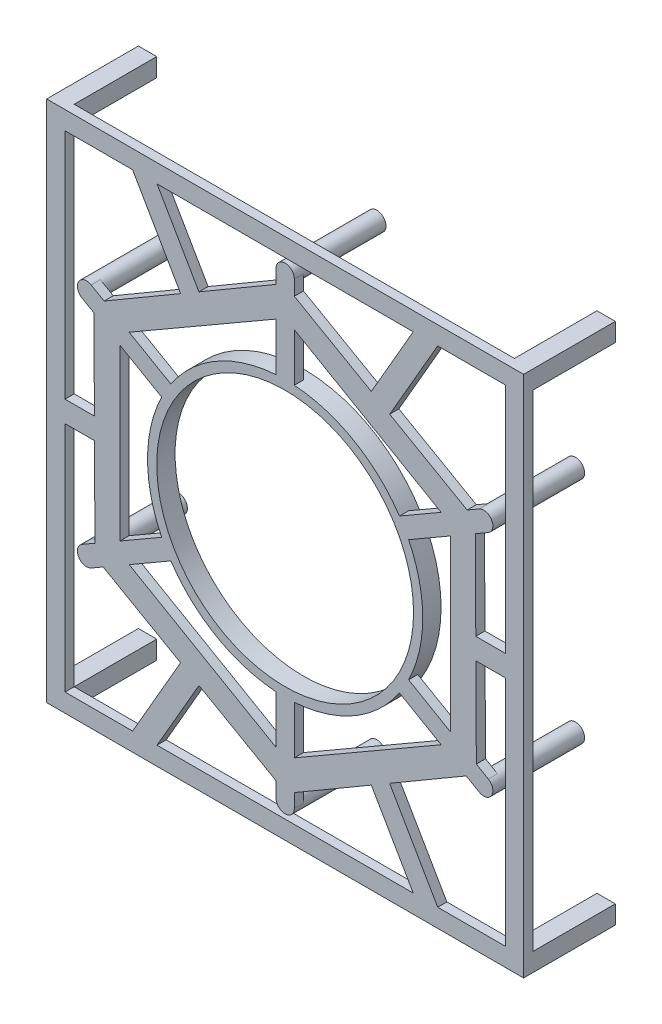
from build123d import *

# Parameters (mm, degrees)
BOSS_EXTRUDE1_DEPTH      = 3.175
BOSS_EXTRUDE2_DEPTH      = 3.175
BOSS_EXTRUDE3_DEPTH      = 3.175
SKETCH1_7_R              = 3.175
BOSS_EXTRUDE4_DEPTH      = 3.175
BOSS_EXTRUDE4_DEPTH_BACK = 28.575
BOSS_EXTRUDE5_DEPTH      = 3.175
BOSS_EXTRUDE5_DEPTH_BACK = 3.175
BOSS_EXTRUDE6_DEPTH      = 3.175
SKETCH1_10_W             = 6.35
SKETCH1_10_H             = 6.35
BOSS_EXTRUDE7_DEPTH      = 3.175
BOSS_EXTRUDE7_DEPTH_BACK = 28.575
SKETCH1_11_W             = 6.35
SKETCH1_11_H             = 80.471325791
BOSS_EXTRUDE8_DEPTH      = 3.175


with BuildPart() as part:
    # Sketch1 → Boss-Extrude1 (new body)
    with BuildSketch(Plane.XY):
        Polygon((-65.842778279, -34.348171554), (-57.167418256, -29.33945011), (-57.167418256, -3.666174209), (-65.993982871, -3.666174209), align=None)
        Polygon((-31.758709128, -47.675349374), (-53.992418256, -34.838711424), (-63.007288153, -40.043448985), (-36.190058785, -55.350672126), align=None)
        Polygon((-57.167418256, -33.005624319), (-57.167418256, -29.33945011), (-65.842778279, -34.348171554), (-65.822630715, -38.436456845), (-63.007288153, -40.043448985), (-53.992418256, -34.838711424), align=None)
        Polygon((-57.167418256, -3.666174209), (-57.167418256, 3.666174209), (-66.03011757, 3.666174209), (-65.993982871, -3.666174209), align=None)
        Polygon((-57.167418256, 3.666174209), (-57.167418256, 29.33945011), (-66.182288153, 34.544187671), (-66.03011757, 3.666174209), align=None)
        Polygon((-66.182288153, 34.544187671), (-57.167418256, 29.33945011), (-57.167418256, 33.005624319), (-53.992418256, 34.838711424), (-62.667778279, 39.847432868), (-66.198263417, 37.785841921), align=None)
        Polygon((-62.667778279, 39.847432868), (-53.992418256, 34.838711424), (-31.758709128, 47.675349374), (-36.171991435, 55.319378558), align=None)
        Polygon((-31.758709128, 47.675349374), (-25.408709128, 51.341523583), (-29.840058785, 59.016846335), (-36.171991435, 55.319378558), align=None)
        Polygon((-25.408709128, 51.341523583), (-3.175, 64.178161534), (-3.175, 74.587636656), (-29.840058785, 59.016846335), align=None)
        Polygon((-3.175, 74.587636656), (-3.175, 64.178161534), (0, 66.011248638), (3.175, 64.178161534), (3.175, 74.195604423), (-0.375632701, 76.222298766), align=None)
        Polygon((3.175, 74.195604423), (3.175, 64.178161534), (25.408709128, 51.341523583), (29.821991435, 58.985552768), align=None)
        Polygon((29.821991435, 58.985552768), (25.408709128, 51.341523583), (31.758709128, 47.675349374), (36.190058785, 55.350672126), align=None)
        Polygon((31.758709128, 47.675349374), (53.992418256, 34.838711424), (63.007288153, 40.043448985), (36.190058785, 55.350672126), align=None)
        Polygon((65.842778279, 34.348171554), (57.167418256, 29.33945011), (57.167418256, 3.666174209), (65.993982871, 3.666174209), align=None)
        Polygon((57.167418256, 33.005624319), (57.167418256, 29.33945011), (65.842778279, 34.348171554), (65.822630715, 38.436456845), (63.007288153, 40.043448985), (53.992418256, 34.838711424), align=None)
        Polygon((57.167418256, 3.666174209), (57.167418256, -3.666174209), (66.03011757, -3.666174209), (65.993982871, 3.666174209), align=None)
        Polygon((57.167418256, -3.666174209), (57.167418256, -29.33945011), (66.182288153, -34.544187671), (66.03011757, -3.666174209), align=None)
        Polygon((57.167418256, -33.005624319), (53.992418256, -34.838711424), (62.667778279, -39.847432868), (66.198263417, -37.785841921), (66.182288153, -34.544187671), (57.167418256, -29.33945011), align=None)
        Polygon((62.667778279, -39.847432868), (53.992418256, -34.838711424), (31.758709128, -47.675349374), (36.171991435, -55.319378558), align=None)
        Polygon((36.171991435, -55.319378558), (31.758709128, -47.675349374), (25.408709128, -51.341523583), (29.840058785, -59.016846335), align=None)
        Polygon((25.408709128, -51.341523583), (3.175, -64.178161534), (3.175, -74.587636656), (29.840058785, -59.016846335), align=None)
        Polygon((0, -66.011248638), (-3.175, -64.178161534), (-3.175, -74.195604423), (0.375632701, -76.222298766), (3.175, -74.587636656), (3.175, -64.178161534), align=None)
        Polygon((-3.175, -74.195604423), (-3.175, -64.178161534), (-25.408709128, -51.341523583), (-29.821991435, -58.985552768), align=None)
        Polygon((-25.408709128, -51.341523583), (-31.758709128, -47.675349374), (-36.190058785, -55.350672126), (-29.821991435, -58.985552768), align=None)
    extrude(amount=BOSS_EXTRUDE1_DEPTH)

    # Sketch1_3 → Boss-Extrude2 (add)
    with BuildSketch(Plane.XY):
        with BuildLine():
            Line((-57.167418256, 29.33945011), (-42.740203435, 21.009893749))
            ThreePointArc((-42.740203435, 21.009893749), (-41.244459855, 23.8125), (-39.565203435, 26.509155063))
            Line((-39.565203435, 26.509155063), (-53.992418256, 34.838711424))
            Line((-53.992418256, 34.838711424), (-57.167418256, 33.005624319))
            Line((-57.167418256, 33.005624319), (-57.167418256, 29.33945011))
        make_face()
        with BuildLine():
            ThreePointArc((-39.565203435, -26.509155063), (-41.244459855, -23.8125), (-42.740203435, -21.009893749))
            Line((-42.740203435, -21.009893749), (-57.167418256, -29.33945011))
            Line((-57.167418256, -29.33945011), (-57.167418256, -33.005624319))
            Line((-57.167418256, -33.005624319), (-53.992418256, -34.838711424))
            Line((-53.992418256, -34.838711424), (-39.565203435, -26.509155063))
        make_face()
        with BuildLine():
            ThreePointArc((3.175, -47.519048812), (0, -47.625), (-3.175, -47.519048812))
            Line((-3.175, -47.519048812), (-3.175, -64.178161534))
            Line((-3.175, -64.178161534), (0, -66.011248638))
            Line((0, -66.011248638), (3.175, -64.178161534))
            Line((3.175, -64.178161534), (3.175, -47.519048812))
        make_face()
        with BuildLine():
            ThreePointArc((42.740203435, -21.009893749), (41.244459855, -23.8125), (39.565203435, -26.509155063))
            Line((39.565203435, -26.509155063), (53.992418256, -34.838711424))
            Line((53.992418256, -34.838711424), (57.167418256, -33.005624319))
            Line((57.167418256, -33.005624319), (57.167418256, -29.33945011))
            Line((57.167418256, -29.33945011), (42.740203435, -21.009893749))
        make_face()
        with BuildLine():
            Line((-3.175, 64.178161534), (-3.175, 47.519048812))
            ThreePointArc((-3.175, 47.519048812), (0, 47.625), (3.175, 47.519048812))
            Line((3.175, 47.519048812), (3.175, 64.178161534))
            Line((3.175, 64.178161534), (0, 66.011248638))
            Line((0, 66.011248638), (-3.175, 64.178161534))
        make_face()
        with BuildLine():
            ThreePointArc((39.565203435, 26.509155063), (41.244459855, 23.8125), (42.740203435, 21.009893749))
            Line((42.740203435, 21.009893749), (57.167418256, 29.33945011))
            Line((57.167418256, 29.33945011), (57.167418256, 33.005624319))
            Line((57.167418256, 33.005624319), (53.992418256, 34.838711424))
            Line((53.992418256, 34.838711424), (39.565203435, 26.509155063))
        make_face()
    extrude(amount=BOSS_EXTRUDE2_DEPTH)

    # Sketch1_5 → Boss-Extrude3 (add)
    with BuildSketch(Plane.XY):
        with BuildLine():
            Line((-67.153266425, -42.437130657), (-63.007288153, -40.043448985))
            Line((-63.007288153, -40.043448985), (-65.822630715, -38.436456845))
            ThreePointArc((-65.822630715, -38.436456845), (-65.630645376, -39.048929675), (-65.565766425, -39.6875))
            ThreePointArc((-65.565766425, -39.6875), (-65.991135768, -41.275), (-67.153266425, -42.437130657))
        make_face()
        with BuildLine():
            Line((-65.822630715, -38.436456845), (-65.842778279, -34.348171554))
            Line((-65.842778279, -34.348171554), (-70.328266425, -36.937869343))
            ThreePointArc((-70.328266425, -36.937869343), (-67.738724024, -36.674771), (-65.822630715, -38.436456845))
        make_face()
        with BuildLine():
            Line((0.375632701, -76.222298766), (-3.175, -74.195604423))
            Line((-3.175, -74.195604423), (-3.175, -79.375))
            ThreePointArc((-3.175, -79.375), (-2.108078648, -77.000841325), (0.375632701, -76.222298766))
        make_face()
        with BuildLine():
            Line((3.175, -79.375), (3.175, -74.587636656))
            Line((3.175, -74.587636656), (0.375632701, -76.222298766))
            ThreePointArc((0.375632701, -76.222298766), (2.374158675, -77.266921352), (3.175, -79.375))
        make_face()
        with BuildLine():
            Line((-70.328266425, 36.937869343), (-66.182288153, 34.544187671))
            Line((-66.182288153, 34.544187671), (-66.198263417, 37.785841921))
            ThreePointArc((-66.198263417, 37.785841921), (-68.1021961, 36.577378951), (-70.328266425, 36.937869343))
        make_face()
        with BuildLine():
            ThreePointArc((-65.565766425, 39.6875), (-65.728037426, 38.685457599), (-66.198263417, 37.785841921))
            Line((-66.198263417, 37.785841921), (-62.667778279, 39.847432868))
            Line((-62.667778279, 39.847432868), (-67.153266425, 42.437130657))
            ThreePointArc((-67.153266425, 42.437130657), (-65.991135768, 41.275), (-65.565766425, 39.6875))
        make_face()
        with BuildLine():
            Line((-3.175, 79.375), (-3.175, 74.587636656))
            Line((-3.175, 74.587636656), (-0.375632701, 76.222298766))
            ThreePointArc((-0.375632701, 76.222298766), (-2.374158675, 77.266921352), (-3.175, 79.375))
        make_face()
        with BuildLine():
            ThreePointArc((3.175, 79.375), (2.108078648, 77.000841325), (-0.375632701, 76.222298766))
            Line((-0.375632701, 76.222298766), (3.175, 74.195604423))
            Line((3.175, 74.195604423), (3.175, 79.375))
        make_face()
        with BuildLine():
            Line((65.822630715, 38.436456845), (65.842778279, 34.348171554))
            Line((65.842778279, 34.348171554), (70.328266425, 36.937869343))
            ThreePointArc((70.328266425, 36.937869343), (67.738724024, 36.674771), (65.822630715, 38.436456845))
        make_face()
        with BuildLine():
            Line((67.153266425, 42.437130657), (63.007288153, 40.043448985))
            Line((63.007288153, 40.043448985), (65.822630715, 38.436456845))
            ThreePointArc((65.822630715, 38.436456845), (65.728037426, 40.689542401), (67.153266425, 42.437130657))
        make_face()
        with BuildLine():
            Line((66.198263417, -37.785841921), (62.667778279, -39.847432868))
            Line((62.667778279, -39.847432868), (67.153266425, -42.437130657))
            ThreePointArc((67.153266425, -42.437130657), (65.630645376, -40.326070325), (66.198263417, -37.785841921))
        make_face()
        with BuildLine():
            Line((66.182288153, -34.544187671), (66.198263417, -37.785841921))
            ThreePointArc((66.198263417, -37.785841921), (68.1021961, -36.577378951), (70.328266425, -36.937869343))
            Line((70.328266425, -36.937869343), (66.182288153, -34.544187671))
        make_face()
    extrude(amount=BOSS_EXTRUDE3_DEPTH)

    # Sketch1_7 → Boss-Extrude4 (add, two sides)
    with BuildSketch(Plane.XY) as boss_extrude4_sk:
        with Locations((0, -79.375)):
            Circle(SKETCH1_7_R)
        with Locations((0, 79.375)):
            Circle(SKETCH1_7_R)
        with Locations((-68.740766425, 39.6875)):
            Circle(SKETCH1_7_R)
        with Locations((68.740766425, -39.6875)):
            Circle(SKETCH1_7_R)
        with Locations((68.740766425, 39.6875)):
            Circle(SKETCH1_7_R)
        with Locations((-68.740766425, -39.6875)):
            Circle(SKETCH1_7_R)
    extrude(amount=BOSS_EXTRUDE4_DEPTH)
    extrude(boss_extrude4_sk.sketch, amount=-BOSS_EXTRUDE4_DEPTH_BACK)

    # Sketch1_8 → Boss-Extrude5 (add, two sides)
    with BuildSketch(Plane.XY) as boss_extrude5_sk:
        with BuildLine():
            Line((20.566839607, 42.955159569), (18.974275759, 40.196758071))
            ThreePointArc((18.974275759, 40.196758071), (22.225, 38.494829198), (25.324275759, 36.530583861))
            Line((25.324275759, 36.530583861), (26.916839607, 39.28898536))
            ThreePointArc((26.916839607, 39.28898536), (23.8125, 41.244459855), (20.566839607, 42.955159569))
        make_face()
        with BuildLine():
            ThreePointArc((25.324275759, 36.530583861), (31.604586637, 31.256241033), (36.809002526, 24.917861726))
            Line((36.809002526, 24.917861726), (39.565203435, 26.509155063))
            ThreePointArc((39.565203435, 26.509155063), (33.849616355, 33.501404413), (26.916839607, 39.28898536))
            Line((26.916839607, 39.28898536), (25.324275759, 36.530583861))
        make_face()
        with BuildLine():
            ThreePointArc((-36.809002526, -24.917861726), (-38.494829198, -22.225), (-39.984002526, -19.418600412))
            Line((-39.984002526, -19.418600412), (-42.740203435, -21.009893749))
            ThreePointArc((-42.740203435, -21.009893749), (-41.244459855, -23.8125), (-39.565203435, -26.509155063))
            Line((-39.565203435, -26.509155063), (-36.809002526, -24.917861726))
        make_face()
        with BuildLine():
            ThreePointArc((36.809002526, 24.917861726), (38.494829198, 22.225), (39.984002526, 19.418600412))
            Line((39.984002526, 19.418600412), (42.740203435, 21.009893749))
            ThreePointArc((42.740203435, 21.009893749), (41.244459855, 23.8125), (39.565203435, 26.509155063))
            Line((39.565203435, 26.509155063), (36.809002526, 24.917861726))
        make_face()
        with BuildLine():
            Line((42.740203435, 21.009893749), (39.984002526, 19.418600412))
            ThreePointArc((39.984002526, 19.418600412), (42.87099208, 11.742254387), (44.298551519, 3.666174209))
            Line((44.298551519, 3.666174209), (47.483679214, 3.666174209))
            ThreePointArc((47.483679214, 3.666174209), (45.937875461, 12.563925465), (42.740203435, 21.009893749))
        make_face()
        with BuildLine():
            ThreePointArc((44.45, 0), (44.412121741, -1.83465051), (44.298551519, -3.666174209))
            Line((44.298551519, -3.666174209), (47.483679214, -3.666174209))
            ThreePointArc((47.483679214, -3.666174209), (47.589656689, -1.83444848), (47.625, 0))
            ThreePointArc((47.625, 0), (47.589656689, 1.83444848), (47.483679214, 3.666174209))
            Line((47.483679214, 3.666174209), (44.298551519, 3.666174209))
            ThreePointArc((44.298551519, 3.666174209), (44.412121741, 1.83465051), (44.45, 0))
        make_face()
        with BuildLine():
            ThreePointArc((44.298551519, -3.666174209), (42.87099208, -11.742254387), (39.984002526, -19.418600412))
            Line((39.984002526, -19.418600412), (42.740203435, -21.009893749))
            ThreePointArc((42.740203435, -21.009893749), (45.937875461, -12.563925465), (47.483679214, -3.666174209))
            Line((47.483679214, -3.666174209), (44.298551519, -3.666174209))
        make_face()
        with BuildLine():
            Line((-42.740203435, 21.009893749), (-39.984002526, 19.418600412))
            ThreePointArc((-39.984002526, 19.418600412), (-38.494829198, 22.225), (-36.809002526, 24.917861726))
            Line((-36.809002526, 24.917861726), (-39.565203435, 26.509155063))
            ThreePointArc((-39.565203435, 26.509155063), (-41.244459855, 23.8125), (-42.740203435, 21.009893749))
        make_face()
        with BuildLine():
            ThreePointArc((39.984002526, -19.418600412), (38.494829198, -22.225), (36.809002526, -24.917861726))
            Line((36.809002526, -24.917861726), (39.565203435, -26.509155063))
            ThreePointArc((39.565203435, -26.509155063), (41.244459855, -23.8125), (42.740203435, -21.009893749))
            Line((42.740203435, -21.009893749), (39.984002526, -19.418600412))
        make_face()
        with BuildLine():
            Line((39.565203435, -26.509155063), (36.809002526, -24.917861726))
            ThreePointArc((36.809002526, -24.917861726), (31.604586637, -31.256241033), (25.324275759, -36.530583861))
            Line((25.324275759, -36.530583861), (26.916839607, -39.28898536))
            ThreePointArc((26.916839607, -39.28898536), (33.849616355, -33.501404413), (39.565203435, -26.509155063))
        make_face()
        with BuildLine():
            Line((26.916839607, -39.28898536), (25.324275759, -36.530583861))
            ThreePointArc((25.324275759, -36.530583861), (22.225, -38.494829198), (18.974275759, -40.196758071))
            Line((18.974275759, -40.196758071), (20.566839607, -42.955159569))
            ThreePointArc((20.566839607, -42.955159569), (23.8125, -41.244459855), (26.916839607, -39.28898536))
        make_face()
        with BuildLine():
            ThreePointArc((18.974275759, -40.196758071), (11.266405443, -42.99849542), (3.175, -44.336462139))
            Line((3.175, -44.336462139), (3.175, -47.519048812))
            ThreePointArc((3.175, -47.519048812), (12.088259107, -46.065329878), (20.566839607, -42.955159569))
            Line((20.566839607, -42.955159569), (18.974275759, -40.196758071))
        make_face()
        with BuildLine():
            ThreePointArc((3.175, -44.336462139), (0, -44.45), (-3.175, -44.336462139))
            Line((-3.175, -44.336462139), (-3.175, -47.519048812))
            ThreePointArc((-3.175, -47.519048812), (0, -47.625), (3.175, -47.519048812))
            Line((3.175, -47.519048812), (3.175, -44.336462139))
        make_face()
        with BuildLine():
            Line((-3.175, 47.519048812), (-3.175, 44.336462139))
            ThreePointArc((-3.175, 44.336462139), (0, 44.45), (3.175, 44.336462139))
            Line((3.175, 44.336462139), (3.175, 47.519048812))
            ThreePointArc((3.175, 47.519048812), (0, 47.625), (-3.175, 47.519048812))
        make_face()
        with BuildLine():
            Line((-3.175, -47.519048812), (-3.175, -44.336462139))
            ThreePointArc((-3.175, -44.336462139), (-11.266405443, -42.99849542), (-18.974275759, -40.196758071))
            Line((-18.974275759, -40.196758071), (-20.566839607, -42.955159569))
            ThreePointArc((-20.566839607, -42.955159569), (-12.088259107, -46.065329878), (-3.175, -47.519048812))
        make_face()
        with BuildLine():
            ThreePointArc((-18.974275759, -40.196758071), (-22.225, -38.494829198), (-25.324275759, -36.530583861))
            Line((-25.324275759, -36.530583861), (-26.916839607, -39.28898536))
            ThreePointArc((-26.916839607, -39.28898536), (-23.8125, -41.244459855), (-20.566839607, -42.955159569))
            Line((-20.566839607, -42.955159569), (-18.974275759, -40.196758071))
        make_face()
        with BuildLine():
            ThreePointArc((-25.324275759, -36.530583861), (-31.604586637, -31.256241033), (-36.809002526, -24.917861726))
            Line((-36.809002526, -24.917861726), (-39.565203435, -26.509155063))
            ThreePointArc((-39.565203435, -26.509155063), (-33.849616355, -33.501404413), (-26.916839607, -39.28898536))
            Line((-26.916839607, -39.28898536), (-25.324275759, -36.530583861))
        make_face()
        with BuildLine():
            ThreePointArc((-36.809002526, -24.917861726), (-38.494829198, -22.225), (-39.984002526, -19.418600412))
            Line((-39.984002526, -19.418600412), (-42.740203435, -21.009893749))
            ThreePointArc((-42.740203435, -21.009893749), (-41.244459855, -23.8125), (-39.565203435, -26.509155063))
            Line((-39.565203435, -26.509155063), (-36.809002526, -24.917861726))
        make_face()
        with BuildLine():
            ThreePointArc((36.809002526, 24.917861726), (38.494829198, 22.225), (39.984002526, 19.418600412))
            Line((39.984002526, 19.418600412), (42.740203435, 21.009893749))
            ThreePointArc((42.740203435, 21.009893749), (41.244459855, 23.8125), (39.565203435, 26.509155063))
            Line((39.565203435, 26.509155063), (36.809002526, 24.917861726))
        make_face()
        with BuildLine():
            Line((-42.740203435, -21.009893749), (-39.984002526, -19.418600412))
            ThreePointArc((-39.984002526, -19.418600412), (-42.87099208, -11.742254387), (-44.298551519, -3.666174209))
            Line((-44.298551519, -3.666174209), (-47.483679214, -3.666174209))
            ThreePointArc((-47.483679214, -3.666174209), (-45.937875461, -12.563925465), (-42.740203435, -21.009893749))
        make_face()
        with BuildLine():
            ThreePointArc((-44.298551519, -3.666174209), (-44.45, 0), (-44.298551519, 3.666174209))
            Line((-44.298551519, 3.666174209), (-47.483679214, 3.666174209))
            ThreePointArc((-47.483679214, 3.666174209), (-47.625, 0), (-47.483679214, -3.666174209))
            Line((-47.483679214, -3.666174209), (-44.298551519, -3.666174209))
        make_face()
        with BuildLine():
            ThreePointArc((-44.298551519, 3.666174209), (-42.87099208, 11.742254387), (-39.984002526, 19.418600412))
            Line((-39.984002526, 19.418600412), (-42.740203435, 21.009893749))
            ThreePointArc((-42.740203435, 21.009893749), (-45.937875461, 12.563925465), (-47.483679214, 3.666174209))
            Line((-47.483679214, 3.666174209), (-44.298551519, 3.666174209))
        make_face()
        with BuildLine():
            Line((-42.740203435, 21.009893749), (-39.984002526, 19.418600412))
            ThreePointArc((-39.984002526, 19.418600412), (-38.494829198, 22.225), (-36.809002526, 24.917861726))
            Line((-36.809002526, 24.917861726), (-39.565203435, 26.509155063))
            ThreePointArc((-39.565203435, 26.509155063), (-41.244459855, 23.8125), (-42.740203435, 21.009893749))
        make_face()
        with BuildLine():
            ThreePointArc((39.984002526, -19.418600412), (38.494829198, -22.225), (36.809002526, -24.917861726))
            Line((36.809002526, -24.917861726), (39.565203435, -26.509155063))
            ThreePointArc((39.565203435, -26.509155063), (41.244459855, -23.8125), (42.740203435, -21.009893749))
            Line((42.740203435, -21.009893749), (39.984002526, -19.418600412))
        make_face()
        with BuildLine():
            Line((-39.565203435, 26.509155063), (-36.809002526, 24.917861726))
            ThreePointArc((-36.809002526, 24.917861726), (-31.604586637, 31.256241033), (-25.324275759, 36.530583861))
            Line((-25.324275759, 36.530583861), (-26.916839607, 39.28898536))
            ThreePointArc((-26.916839607, 39.28898536), (-33.849616355, 33.501404413), (-39.565203435, 26.509155063))
        make_face()
        with BuildLine():
            ThreePointArc((-25.324275759, 36.530583861), (-22.225, 38.494829198), (-18.974275759, 40.196758071))
            Line((-18.974275759, 40.196758071), (-20.566839607, 42.955159569))
            ThreePointArc((-20.566839607, 42.955159569), (-23.8125, 41.244459855), (-26.916839607, 39.28898536))
            Line((-26.916839607, 39.28898536), (-25.324275759, 36.530583861))
        make_face()
        with BuildLine():
            ThreePointArc((-18.974275759, 40.196758071), (-11.266405443, 42.99849542), (-3.175, 44.336462139))
            Line((-3.175, 44.336462139), (-3.175, 47.519048812))
            ThreePointArc((-3.175, 47.519048812), (-12.088259107, 46.065329878), (-20.566839607, 42.955159569))
            Line((-20.566839607, 42.955159569), (-18.974275759, 40.196758071))
        make_face()
        with BuildLine():
            ThreePointArc((3.175, -44.336462139), (0, -44.45), (-3.175, -44.336462139))
            Line((-3.175, -44.336462139), (-3.175, -47.519048812))
            ThreePointArc((-3.175, -47.519048812), (0, -47.625), (3.175, -47.519048812))
            Line((3.175, -47.519048812), (3.175, -44.336462139))
        make_face()
        with BuildLine():
            Line((-3.175, 47.519048812), (-3.175, 44.336462139))
            ThreePointArc((-3.175, 44.336462139), (0, 44.45), (3.175, 44.336462139))
            Line((3.175, 44.336462139), (3.175, 47.519048812))
            ThreePointArc((3.175, 47.519048812), (0, 47.625), (-3.175, 47.519048812))
        make_face()
        with BuildLine():
            Line((3.175, 47.519048812), (3.175, 44.336462139))
            ThreePointArc((3.175, 44.336462139), (11.266405443, 42.99849542), (18.974275759, 40.196758071))
            Line((18.974275759, 40.196758071), (20.566839607, 42.955159569))
            ThreePointArc((20.566839607, 42.955159569), (12.088259107, 46.065329878), (3.175, 47.519048812))
        make_face()
    extrude(amount=BOSS_EXTRUDE5_DEPTH)
    extrude(boss_extrude5_sk.sketch, amount=-BOSS_EXTRUDE5_DEPTH_BACK)

    # Sketch1_9 → Boss-Extrude6 (add)
    with BuildSketch(Plane.XY):
        Polygon((-65.993982871, -3.666174209), (-66.03011757, 3.666174209), (-82.55, 3.666174209), (-82.55, -3.666174209), align=None)
        Polygon((-29.821991435, -58.985552768), (-36.190058785, -55.350672126), (-52.810141607, -84.1375), (-76.2, -84.1375), (-76.2, -90.4875), (76.2, -90.4875), (76.2, -84.1375), (52.810141607, -84.1375), (36.171991435, -55.319378558), (29.840058785, -59.016846335), (44.343474941, -84.1375), (-44.343474941, -84.1375), align=None)
        Polygon((-36.171991435, 55.319378558), (-29.840058785, 59.016846335), (-44.343474941, 84.1375), (44.343474941, 84.1375), (29.821991435, 58.985552768), (36.190058785, 55.350672126), (52.810141607, 84.1375), (76.2, 84.1375), (76.2, 90.4875), (-76.2, 90.4875), (-76.2, 84.1375), (-52.810141607, 84.1375), align=None)
        Polygon((65.993982871, 3.666174209), (66.03011757, -3.666174209), (82.55, -3.666174209), (82.55, 3.666174209), align=None)
    extrude(amount=BOSS_EXTRUDE6_DEPTH)

    # Sketch1_10 → Boss-Extrude7 (add, two sides)
    with BuildSketch(Plane.XY) as boss_extrude7_sk:
        with Locations((79.375, -87.3125)):
            Rectangle(SKETCH1_10_W, SKETCH1_10_H)
        with Locations((-79.375, -87.3125)):
            Rectangle(SKETCH1_10_W, SKETCH1_10_H)
        with Locations((-79.375, 87.3125)):
            Rectangle(SKETCH1_10_W, SKETCH1_10_H)
        with Locations((79.375, 87.3125)):
            Rectangle(SKETCH1_10_W, SKETCH1_10_H)
    extrude(amount=BOSS_EXTRUDE7_DEPTH)
    extrude(boss_extrude7_sk.sketch, amount=-BOSS_EXTRUDE7_DEPTH_BACK)

    # Sketch1_11 → Boss-Extrude8 (add)
    with BuildSketch(Plane.XY):
        with Locations((-79.375, -43.901837105)):
            Rectangle(SKETCH1_11_W, SKETCH1_11_H)
        with Locations((-79.375, 43.901837105)):
            Rectangle(SKETCH1_11_W, SKETCH1_11_H)
        with Locations((79.375, 43.901837105)):
            Rectangle(SKETCH1_11_W, SKETCH1_11_H)
        with Locations((79.375, -43.901837105)):
            Rectangle(SKETCH1_11_W, SKETCH1_11_H)
    extrude(amount=BOSS_EXTRUDE8_DEPTH)


solid = part.part
